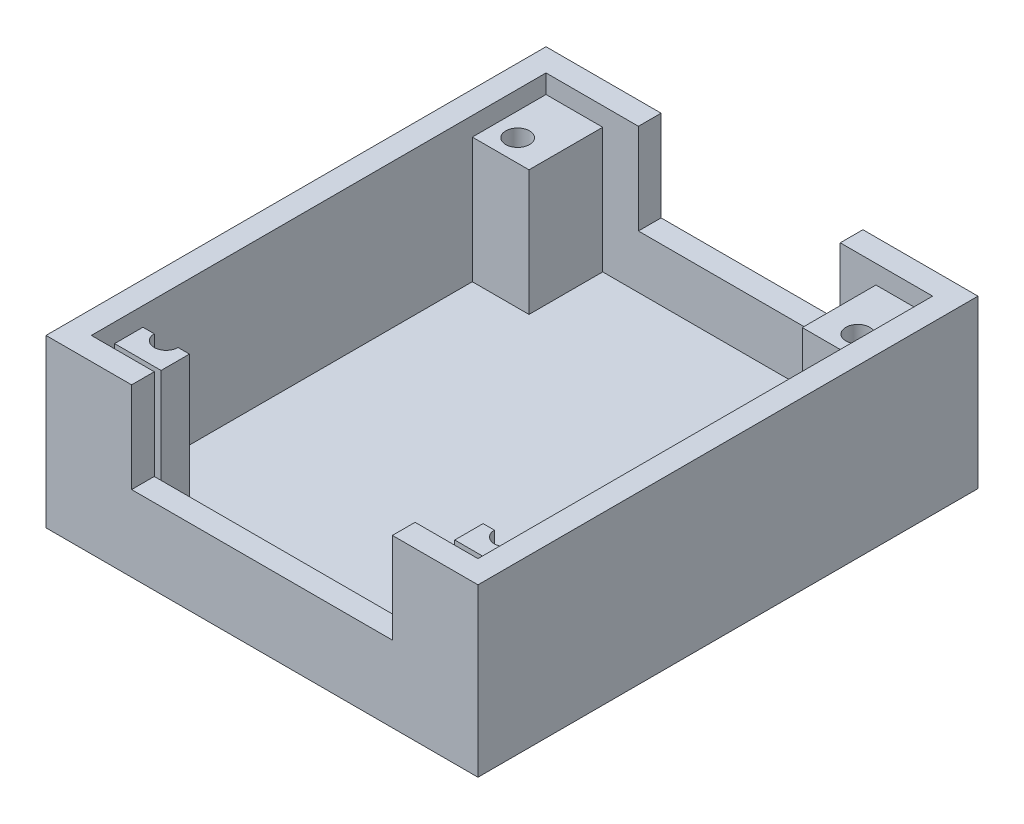
from build123d import *
from build123d.topology import SkipClean

# Parameters (mm, degrees)
BOSS_EXTRUDE1_DEPTH                        = 2
BOSS_EXTRUDE2_DEPTH                        = 12.7
BOSS_EXTRUDE2_DEPTH_BACK                   = 2
SKETCH2_W                                  = 38.1
SKETCH2_H                                  = 44.1
SKETCH2_W_2                                = 34.1
SKETCH2_H_2                                = 40.1
SKETCH4_W                                  = 17.8
SKETCH4_H                                  = 2
SKETCH4_W_2                                = 23
CUT_EXTRUDE1_DEPTH                         = 8
SKETCH5_W                                  = 5
SKETCH5_H                                  = 6.5
BOSS_EXTRUDE3_DEPTH                        = 11.05
SKETCH3_R                                  = 1.05
CUT_EXTRUDE2_DEPTH                         = 33.637325258
MIRROR1_AT_THE_SECOND_PLANE_COPY_1_SKETC_R = 1.05
MIRROR1_AT_THE_SECOND_PLANE_COPY_1_DEPTH   = 33.637325258


with BuildPart() as part:
    # Sketch1 → Boss-Extrude1 (new body)
    with BuildSketch(Plane(origin=(0, 0, 0), x_dir=(1, 0, 0), z_dir=(0, 1, 0))):
        Polygon((-17.05, 20.05), (-17.05, -20.05), (17.05, -20.05), align=None)
        Polygon((17.05, 20.05), (17.05, -20.05), (-17.05, 20.05), align=None)
    extrude(amount=BOSS_EXTRUDE1_DEPTH)

    # Sketch2 → Boss-Extrude2 (add, two sides: drawn at the far end of the back side and taken through both)
    with BuildSketch(Plane(origin=(0, 2, 0), x_dir=(1, 0, 0), z_dir=(0, 1, 0)).offset(-BOSS_EXTRUDE2_DEPTH_BACK)):
        Rectangle(SKETCH2_W, SKETCH2_H)
        Rectangle(SKETCH2_W_2, SKETCH2_H_2, mode=Mode.SUBTRACT)
    extrude(amount=BOSS_EXTRUDE2_DEPTH + BOSS_EXTRUDE2_DEPTH_BACK)

    # Sketch4 → Cut-Extrude1 (cut)
    with BuildSketch(Plane(origin=(0, 14.7, 0), x_dir=(1, 0, 0), z_dir=(0, 1, 0))):
        with Locations((0, 21.05)):
            Rectangle(SKETCH4_W, SKETCH4_H)
        with Locations((0, -21.05)):
            Rectangle(SKETCH4_W_2, SKETCH4_H)
    extrude(amount=-CUT_EXTRUDE1_DEPTH, mode=Mode.SUBTRACT)

    # Sketch5 → Boss-Extrude3 (add)
    with BuildSketch(Plane(origin=(0, 2, 0), x_dir=(1, 0, 0), z_dir=(0, 1, 0))):
        with BuildLine():
            ThreePointArc((-13.95, -15.5), (-15, -16.55), (-16.05, -15.5))
            Line((-16.05, -15.5), (-17.05, -15.5))
            Line((-17.05, -15.5), (-17.05, -18))
            Line((-17.05, -18), (-12.95, -18))
            Line((-12.95, -18), (-12.95, -15.5))
            Line((-12.95, -15.5), (-13.95, -15.5))
        make_face()
        with Locations((-14.55, 16.8)):
            Rectangle(SKETCH5_W, SKETCH5_H)
        with Locations((14.55, 16.8)):
            Rectangle(SKETCH5_W, SKETCH5_H)
        with BuildLine():
            Line((13.95, -15.5), (12.95, -15.5))
            Line((12.95, -15.5), (12.95, -18))
            Line((12.95, -18), (17.05, -18))
            Line((17.05, -18), (17.05, -15.5))
            Line((17.05, -15.5), (16.05, -15.5))
            ThreePointArc((16.05, -15.5), (15, -16.55), (13.95, -15.5))
        make_face()
    extrude(amount=BOSS_EXTRUDE3_DEPTH)

    # Sketch3 → Cut-Extrude2 (cut, through all)
    with BuildSketch(Plane.XZ):
        with Locations(Location((-15, 15.5, 0), (0, 0, 270))):
            Circle(SKETCH3_R)
    cut_extrude2 = extrude(amount=-CUT_EXTRUDE2_DEPTH, mode=Mode.SUBTRACT)

    # Mirror1: Cut-Extrude2 across plane
    add(cut_extrude2.mirror(Plane.XY), mode=Mode.SUBTRACT)

    # Mirror1 at the second plane: Cut-Extrude2 across plane
    with SkipClean():  # the faces are left unmerged after this step: merging them gives an invalid solid
        add(cut_extrude2.mirror(Plane(origin=(0, 0, 0), x_dir=(0, 0, 1), z_dir=(1, 0, 0))), mode=Mode.SUBTRACT)

    # Mirror1 at the second plane copy 1 sketc → Mirror1 at the second plane copy 1 (cut, through all)
    with SkipClean():  # the faces are left unmerged after this step: merging them gives an invalid solid
        with BuildSketch(Plane(origin=(0, 0, 0), x_dir=(-1, 0, 0), z_dir=(0, -1, 0))):
            with Locations(Location((-15, 15.5, 0), (0, 0, 270))):
                Circle(MIRROR1_AT_THE_SECOND_PLANE_COPY_1_SKETC_R)
        extrude(amount=-MIRROR1_AT_THE_SECOND_PLANE_COPY_1_DEPTH, mode=Mode.SUBTRACT)


solid = part.part
